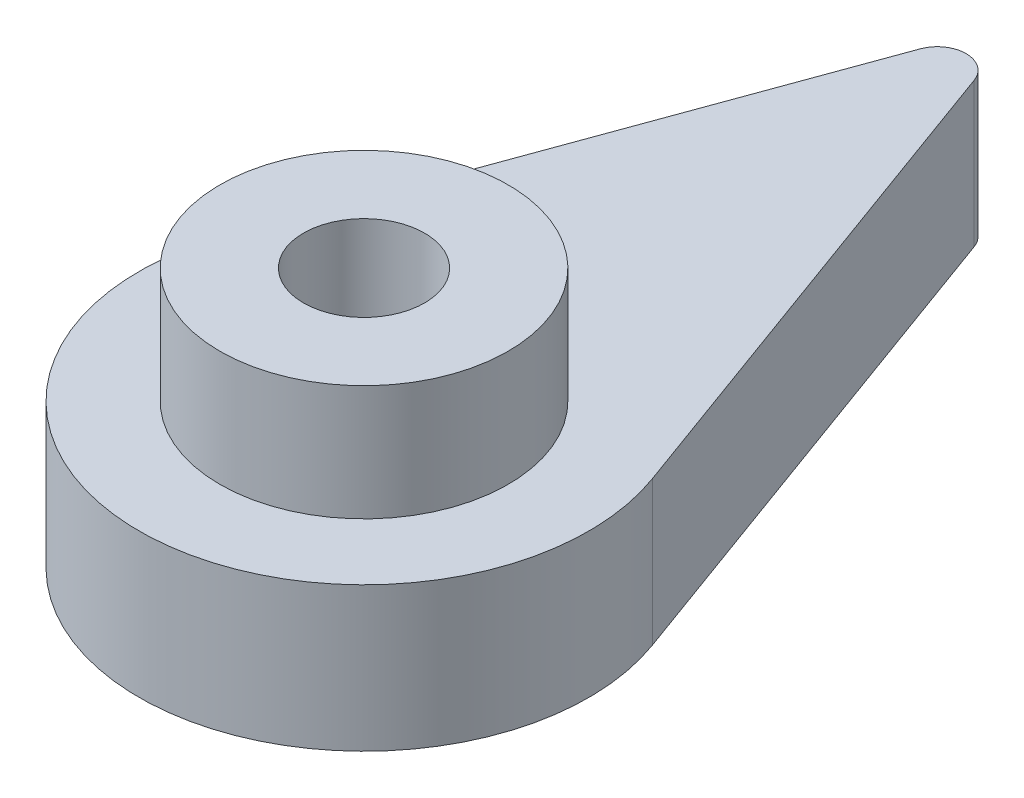
from build123d import *

# Parameters (mm, degrees)
BOSS_EXTRUDE2_DEPTH = 5
CUT_EXTRUDE1_REACH  = 7
SKETCH3_R           = 2.1
CUT_EXTRUDE3_DEPTH  = 1.8
SKETCH6_R           = 5
SKETCH6_R_2         = 2.1
BOSS_EXTRUDE3_DEPTH = 4


with BuildPart() as part:
    # Sketch1 → Boss-Extrude2 (new body)
    with BuildSketch(Plane(origin=(0, 0, 0), x_dir=(1, 0, 0), z_dir=(0, 1, 0))):
        with BuildLine():
            Line((-0.939692556, 20.223890242), (-7.329602442, 2.667757118))
            ThreePointArc((-7.329602442, 2.667757118), (0, -7.8), (7.329602442, 2.667757118))
            Line((7.329602442, 2.667757118), (0.939692556, 20.223890242))
            ThreePointArc((0.939692556, 20.223890242), (0, 20.881870053), (-0.939692556, 20.223890242))
        make_face()
    extrude(amount=BOSS_EXTRUDE2_DEPTH)

    # Sketch3 → Cut-Extrude1 (cut, up to next)
    with BuildSketch(Plane(origin=(0, 5, 0), x_dir=(1, 0, 0), z_dir=(0, 1, 0)), mode=Mode.PRIVATE) as cut_extrude1_sk1:
        Circle(SKETCH3_R)
    cut_extrude1_tool1 = extrude(cut_extrude1_sk1.sketch, amount=-CUT_EXTRUDE1_REACH, mode=Mode.PRIVATE) & part.part
    add(cut_extrude1_tool1.solids().sort_by_distance((0, 5, 0))[0], mode=Mode.SUBTRACT)

    # Sketch5 → Cut-Extrude3 (cut)
    with BuildSketch(Plane.XZ):
        Polygon((0, 4.272391992), (-3.7, 2.136195996), (-3.7, -2.136195996), (0, -4.272391992), (3.7, -2.136195996), (3.7, 2.136195996), align=None)
    extrude(amount=-CUT_EXTRUDE3_DEPTH, mode=Mode.SUBTRACT)

    # Sketch6 → Boss-Extrude3 (add)
    with BuildSketch(Plane(origin=(0, 5, 0), x_dir=(1, 0, 0), z_dir=(0, 1, 0))):
        Circle(SKETCH6_R)
        Circle(SKETCH6_R_2, mode=Mode.SUBTRACT)
    extrude(amount=BOSS_EXTRUDE3_DEPTH)


solid = part.part
